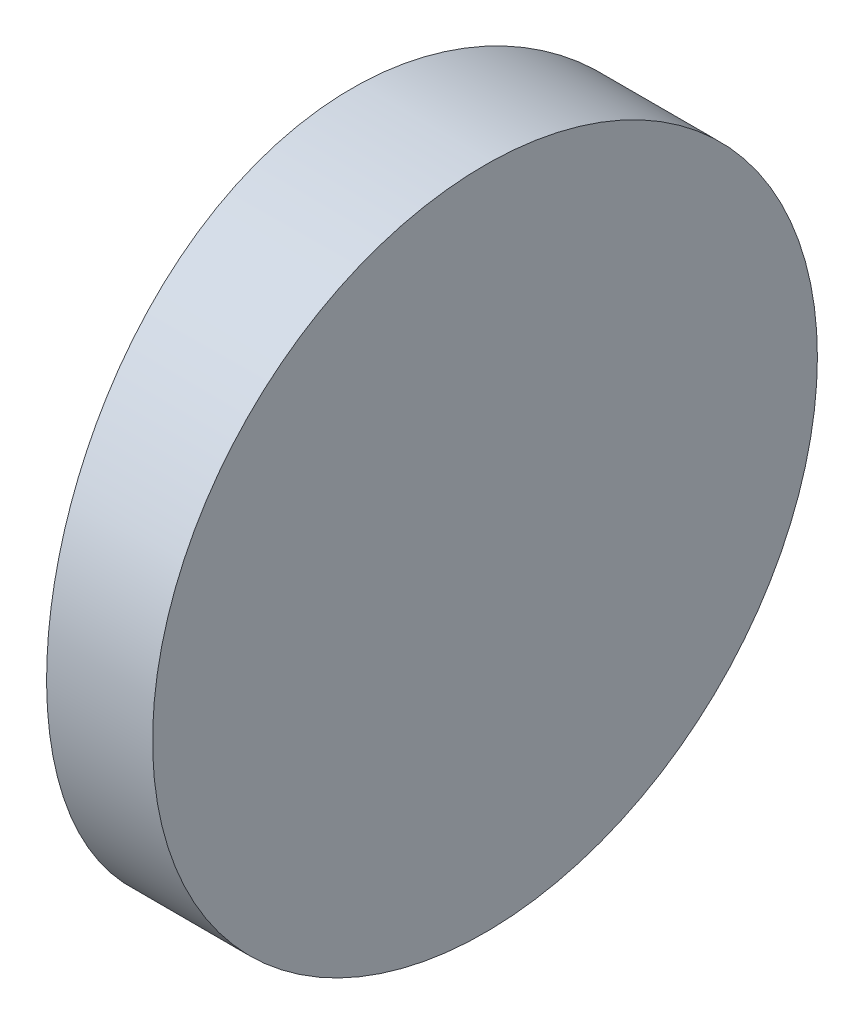
from build123d import *

# Parameters (mm, degrees)
EXTRUDE_1_DEPTH     = 12.5
CUT_EXTRUDE_8_DEPTH = 12.7


with BuildPart() as part:
    # 草图1 → 凸台-拉伸1 (new body)
    with BuildSketch(Plane(origin=(0, 0, 0), x_dir=(1, 0, 0), z_dir=(0, 1, 0))):
        with BuildLine():
            Line((-33.917839704, 6.25), (-31.924795665, 6.25))
            Line((-31.924795665, 6.25), (-31.924795665, -6.25))
            Line((-31.924795665, -6.25), (-33.917839704, -6.25))
            ThreePointArc((-33.917839704, -6.25), (-34.424795665, 0), (-33.917839704, 6.25))
        make_face()
    extrude(amount=EXTRUDE_1_DEPTH)

    # 草图2 → 切除-拉伸8 (cut)
    with BuildSketch(Plane(origin=(-31.924795665, 0, 0), x_dir=(0, 0, -1), z_dir=(1, 0, 0))):
        with BuildLine():
            Line((-6.25, 12.5), (-6.25, 6.250000013))
            ThreePointArc((-6.25, 6.250000013), (-4.419417378, 10.669417387), (0, 12.5))
            Line((0, 12.5), (-6.25, 12.5))
        make_face()
        with BuildLine():
            ThreePointArc((0, 12.5), (4.419417382, 10.669417382), (6.25, 6.25))
            Line((6.25, 6.25), (6.25, 12.5))
            Line((6.25, 12.5), (0, 12.5))
        make_face()
        with BuildLine():
            ThreePointArc((6.25, 6.25), (4.419417382, 1.830582618), (0, 0))
            Line((0, 0), (6.25, 0))
            Line((6.25, 0), (6.25, 6.25))
        make_face()
        with BuildLine():
            Line((-6.25, 6.250000013), (-6.25, 0))
            Line((-6.25, 0), (0, 0))
            ThreePointArc((0, 0), (-4.419417387, 1.830582622), (-6.25, 6.250000013))
        make_face()
    extrude(amount=-CUT_EXTRUDE_8_DEPTH, mode=Mode.SUBTRACT)


solid = part.part
